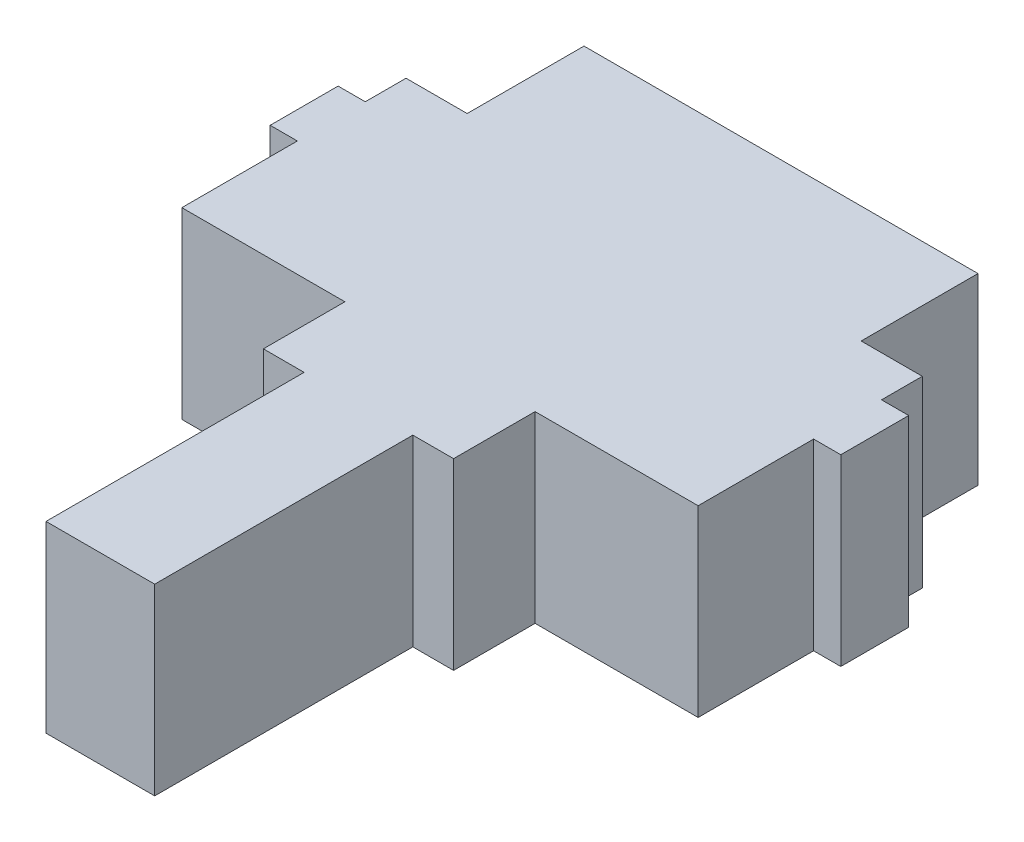
from build123d import *

# Parameters (mm, degrees)
BOSS_EXTRUDE1_DEPTH = 13.5
SKETCH2_R           = 2.5
BOSS_EXTRUDE2_DEPTH = 2.5


with BuildPart() as part:
    # Sketch1 → Boss-Extrude1 (new body)
    with BuildSketch(Plane(origin=(0, 0, 0), x_dir=(1, 0, 0), z_dir=(0, 1, 0))):
        Polygon((30.066607979, 23.493934911), (30.066607979, 4.493934911), (38.066607979, 4.493934911), (38.066607979, 23.493934911), (41.066607979, 23.493934911), (41.066607979, 29.493934911), (53.066607979, 29.493934911), (53.066607979, 37.993934911), (55.066607979, 37.993934911), (55.066607979, 42.993934911), (53.066607979, 42.993934911), (53.066607979, 45.993934911), (48.566607979, 45.993934911), (48.566607979, 54.593934911), (43.066607979, 54.593934911), (25.066607979, 54.593934911), (19.566607979, 54.593934911), (19.566607979, 45.993934911), (15.066607979, 45.993934911), (15.066607979, 42.993934911), (13.066607979, 42.993934911), (13.066607979, 37.993934911), (15.066607979, 37.993934911), (15.066607979, 29.493934911), (27.066607979, 29.493934911), (27.066607979, 23.493934911), align=None)
    extrude(amount=BOSS_EXTRUDE1_DEPTH)

    # Sketch2 → Boss-Extrude2 (add)
    with BuildSketch(Plane.XZ):
        with Locations((34.066607979, -32.993934911)):
            Circle(SKETCH2_R)
    extrude(amount=BOSS_EXTRUDE2_DEPTH)


solid = part.part
